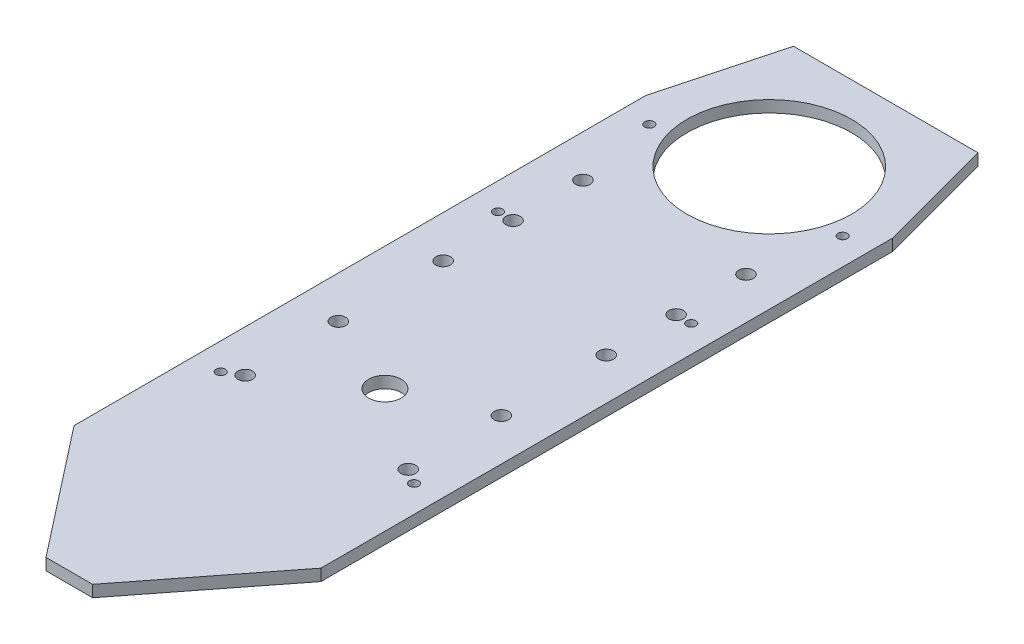
from build123d import *

# Parameters (mm, degrees)
SKETCH23_R          = 70.65
SKETCH23_R_2        = 14
BOSS_EXTRUDE3_DEPTH = 10
LO_BAT_HOP_SO_REACH = 12
SKETCH24_R          = 4
SKETCH24_R_2        = 6.25


with BuildPart() as part:
    # Sketch23 → Boss-Extrude3 (new body)
    with BuildSketch(Plane(origin=(0, 0, 0), x_dir=(1, 0, 0), z_dir=(0, 1, 0))):
        Polygon((106, -490.925019631), (106, 0), (79.205080757, 100), (-79.205080757, 100), (-106, 0), (-106, -490.925019631), (-20, -601), (20, -601), align=None)
        Circle(SKETCH23_R, mode=Mode.SUBTRACT)
        with Locations((0, -330)):
            Circle(SKETCH23_R_2, mode=Mode.SUBTRACT)
    extrude(amount=BOSS_EXTRUDE3_DEPTH)

    # Sketch24 → lo bat hop so (cut, up to next)
    with BuildSketch(Plane(origin=(0, 10, 0), x_dir=(1, 0, 0), z_dir=(0, 1, 0)), mode=Mode.PRIVATE) as lo_bat_hop_so_sk1:
        with Locations((-83, -150)):
            Circle(SKETCH24_R)
    lo_bat_hop_so_tool1 = extrude(lo_bat_hop_so_sk1.sketch, amount=-LO_BAT_HOP_SO_REACH, mode=Mode.PRIVATE) & part.part
    add(lo_bat_hop_so_tool1.solids().sort_by_distance((-83, 10, 150))[0], mode=Mode.SUBTRACT)
    # Sketch24 → lo bat hop so (cut, up to next)
    with BuildSketch(Plane(origin=(0, 10, 0), x_dir=(1, 0, 0), z_dir=(0, 1, 0)), mode=Mode.PRIVATE) as lo_bat_hop_so_sk2:
        with Locations((-83, -388)):
            Circle(SKETCH24_R)
    lo_bat_hop_so_tool2 = extrude(lo_bat_hop_so_sk2.sketch, amount=-LO_BAT_HOP_SO_REACH, mode=Mode.PRIVATE) & part.part
    add(lo_bat_hop_so_tool2.solids().sort_by_distance((-83, 10, 388))[0], mode=Mode.SUBTRACT)
    # Sketch24 → lo bat hop so (cut, up to next)
    with BuildSketch(Plane(origin=(0, 10, 0), x_dir=(1, 0, 0), z_dir=(0, 1, 0)), mode=Mode.PRIVATE) as lo_bat_hop_so_sk3:
        with Locations((83, -388)):
            Circle(SKETCH24_R)
    lo_bat_hop_so_tool3 = extrude(lo_bat_hop_so_sk3.sketch, amount=-LO_BAT_HOP_SO_REACH, mode=Mode.PRIVATE) & part.part
    add(lo_bat_hop_so_tool3.solids().sort_by_distance((83, 10, 388))[0], mode=Mode.SUBTRACT)
    # Sketch24 → lo bat hop so (cut, up to next)
    with BuildSketch(Plane(origin=(0, 10, 0), x_dir=(1, 0, 0), z_dir=(0, 1, 0)), mode=Mode.PRIVATE) as lo_bat_hop_so_sk4:
        with Locations((83, -150)):
            Circle(SKETCH24_R)
    lo_bat_hop_so_tool4 = extrude(lo_bat_hop_so_sk4.sketch, amount=-LO_BAT_HOP_SO_REACH, mode=Mode.PRIVATE) & part.part
    add(lo_bat_hop_so_tool4.solids().sort_by_distance((83, 10, 150))[0], mode=Mode.SUBTRACT)
    # Sketch24 → lo bat hop so (cut, up to next)
    with BuildSketch(Plane(origin=(0, 10, 0), x_dir=(1, 0, 0), z_dir=(0, 1, 0)), mode=Mode.PRIVATE) as lo_bat_hop_so_sk5:
        with Locations((-83, -20)):
            Circle(SKETCH24_R)
    lo_bat_hop_so_tool5 = extrude(lo_bat_hop_so_sk5.sketch, amount=-LO_BAT_HOP_SO_REACH, mode=Mode.PRIVATE) & part.part
    add(lo_bat_hop_so_tool5.solids().sort_by_distance((-83, 10, 20))[0], mode=Mode.SUBTRACT)
    # Sketch24 → lo bat hop so (cut, up to next)
    with BuildSketch(Plane(origin=(0, 10, 0), x_dir=(1, 0, 0), z_dir=(0, 1, 0)), mode=Mode.PRIVATE) as lo_bat_hop_so_sk6:
        with Locations((83, -20)):
            Circle(SKETCH24_R)
    lo_bat_hop_so_tool6 = extrude(lo_bat_hop_so_sk6.sketch, amount=-LO_BAT_HOP_SO_REACH, mode=Mode.PRIVATE) & part.part
    add(lo_bat_hop_so_tool6.solids().sort_by_distance((83, 10, 20))[0], mode=Mode.SUBTRACT)
    # Sketch24 → lo bat hop so (cut, up to next)
    with BuildSketch(Plane(origin=(0, 10, 0), x_dir=(1, 0, 0), z_dir=(0, 1, 0)), mode=Mode.PRIVATE) as lo_bat_hop_so_sk7:
        with Locations((-70, -380)):
            Circle(SKETCH24_R_2)
    lo_bat_hop_so_tool7 = extrude(lo_bat_hop_so_sk7.sketch, amount=-LO_BAT_HOP_SO_REACH, mode=Mode.PRIVATE) & part.part
    add(lo_bat_hop_so_tool7.solids().sort_by_distance((-70, 10, 380))[0], mode=Mode.SUBTRACT)
    # Sketch24 → lo bat hop so (cut, up to next)
    with BuildSketch(Plane(origin=(0, 10, 0), x_dir=(1, 0, 0), z_dir=(0, 1, 0)), mode=Mode.PRIVATE) as lo_bat_hop_so_sk8:
        with Locations((-70, -300)):
            Circle(SKETCH24_R_2)
    lo_bat_hop_so_tool8 = extrude(lo_bat_hop_so_sk8.sketch, amount=-LO_BAT_HOP_SO_REACH, mode=Mode.PRIVATE) & part.part
    add(lo_bat_hop_so_tool8.solids().sort_by_distance((-70, 10, 300))[0], mode=Mode.SUBTRACT)
    # Sketch24 → lo bat hop so (cut, up to next)
    with BuildSketch(Plane(origin=(0, 10, 0), x_dir=(1, 0, 0), z_dir=(0, 1, 0)), mode=Mode.PRIVATE) as lo_bat_hop_so_sk9:
        with Locations((-70, -210)):
            Circle(SKETCH24_R_2)
    lo_bat_hop_so_tool9 = extrude(lo_bat_hop_so_sk9.sketch, amount=-LO_BAT_HOP_SO_REACH, mode=Mode.PRIVATE) & part.part
    add(lo_bat_hop_so_tool9.solids().sort_by_distance((-70, 10, 210))[0], mode=Mode.SUBTRACT)
    # Sketch24 → lo bat hop so (cut, up to next)
    with BuildSketch(Plane(origin=(0, 10, 0), x_dir=(1, 0, 0), z_dir=(0, 1, 0)), mode=Mode.PRIVATE) as lo_bat_hop_so_sk10:
        with Locations((-70, -150)):
            Circle(SKETCH24_R_2)
    lo_bat_hop_so_tool10 = extrude(lo_bat_hop_so_sk10.sketch, amount=-LO_BAT_HOP_SO_REACH, mode=Mode.PRIVATE) & part.part
    add(lo_bat_hop_so_tool10.solids().sort_by_distance((-70, 10, 150))[0], mode=Mode.SUBTRACT)
    # Sketch24 → lo bat hop so (cut, up to next)
    with BuildSketch(Plane(origin=(0, 10, 0), x_dir=(1, 0, 0), z_dir=(0, 1, 0)), mode=Mode.PRIVATE) as lo_bat_hop_so_sk11:
        with Locations((-70, -90)):
            Circle(SKETCH24_R_2)
    lo_bat_hop_so_tool11 = extrude(lo_bat_hop_so_sk11.sketch, amount=-LO_BAT_HOP_SO_REACH, mode=Mode.PRIVATE) & part.part
    add(lo_bat_hop_so_tool11.solids().sort_by_distance((-70, 10, 90))[0], mode=Mode.SUBTRACT)
    # Sketch24 → lo bat hop so (cut, up to next)
    with BuildSketch(Plane(origin=(0, 10, 0), x_dir=(1, 0, 0), z_dir=(0, 1, 0)), mode=Mode.PRIVATE) as lo_bat_hop_so_sk12:
        with Locations((70, -90)):
            Circle(SKETCH24_R_2)
    lo_bat_hop_so_tool12 = extrude(lo_bat_hop_so_sk12.sketch, amount=-LO_BAT_HOP_SO_REACH, mode=Mode.PRIVATE) & part.part
    add(lo_bat_hop_so_tool12.solids().sort_by_distance((70, 10, 90))[0], mode=Mode.SUBTRACT)
    # Sketch24 → lo bat hop so (cut, up to next)
    with BuildSketch(Plane(origin=(0, 10, 0), x_dir=(1, 0, 0), z_dir=(0, 1, 0)), mode=Mode.PRIVATE) as lo_bat_hop_so_sk13:
        with Locations((70, -150)):
            Circle(SKETCH24_R_2)
    lo_bat_hop_so_tool13 = extrude(lo_bat_hop_so_sk13.sketch, amount=-LO_BAT_HOP_SO_REACH, mode=Mode.PRIVATE) & part.part
    add(lo_bat_hop_so_tool13.solids().sort_by_distance((70, 10, 150))[0], mode=Mode.SUBTRACT)
    # Sketch24 → lo bat hop so (cut, up to next)
    with BuildSketch(Plane(origin=(0, 10, 0), x_dir=(1, 0, 0), z_dir=(0, 1, 0)), mode=Mode.PRIVATE) as lo_bat_hop_so_sk14:
        with Locations((70, -210)):
            Circle(SKETCH24_R_2)
    lo_bat_hop_so_tool14 = extrude(lo_bat_hop_so_sk14.sketch, amount=-LO_BAT_HOP_SO_REACH, mode=Mode.PRIVATE) & part.part
    add(lo_bat_hop_so_tool14.solids().sort_by_distance((70, 10, 210))[0], mode=Mode.SUBTRACT)
    # Sketch24 → lo bat hop so (cut, up to next)
    with BuildSketch(Plane(origin=(0, 10, 0), x_dir=(1, 0, 0), z_dir=(0, 1, 0)), mode=Mode.PRIVATE) as lo_bat_hop_so_sk15:
        with Locations((70, -300)):
            Circle(SKETCH24_R_2)
    lo_bat_hop_so_tool15 = extrude(lo_bat_hop_so_sk15.sketch, amount=-LO_BAT_HOP_SO_REACH, mode=Mode.PRIVATE) & part.part
    add(lo_bat_hop_so_tool15.solids().sort_by_distance((70, 10, 300))[0], mode=Mode.SUBTRACT)
    # Sketch24 → lo bat hop so (cut, up to next)
    with BuildSketch(Plane(origin=(0, 10, 0), x_dir=(1, 0, 0), z_dir=(0, 1, 0)), mode=Mode.PRIVATE) as lo_bat_hop_so_sk16:
        with Locations((70, -380)):
            Circle(SKETCH24_R_2)
    lo_bat_hop_so_tool16 = extrude(lo_bat_hop_so_sk16.sketch, amount=-LO_BAT_HOP_SO_REACH, mode=Mode.PRIVATE) & part.part
    add(lo_bat_hop_so_tool16.solids().sort_by_distance((70, 10, 380))[0], mode=Mode.SUBTRACT)


solid = part.part
